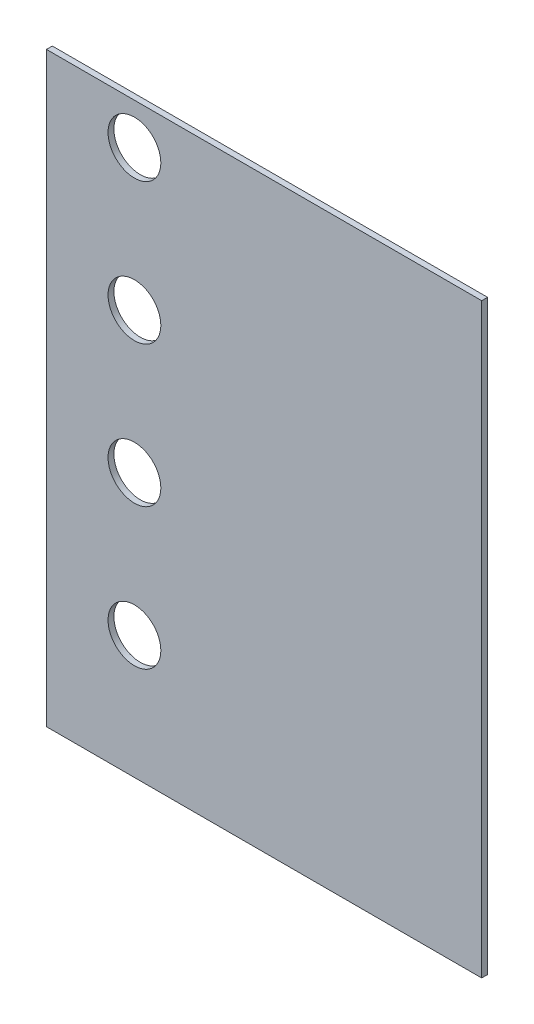
from build123d import *

# Parameters (mm, degrees)
SKETCH1_W           = 246.38
SKETCH1_H           = 254
BOSS_EXTRUDE1_DEPTH = 2.54
SKETCH3_R           = 11.43
CUT_EXTRUDE1_DEPTH  = 3.54
LPATTERN1_COUNT     = 4
LPATTERN1_PITCH     = 60.96
SKETCH4_W           = 57.912
SKETCH4_H           = 254
CUT_EXTRUDE2_DEPTH  = 3.54


with BuildPart() as part:
    # Sketch1 → Boss-Extrude1 (new body)
    with BuildSketch(Plane.XY):
        Rectangle(SKETCH1_W, SKETCH1_H)
    extrude(amount=BOSS_EXTRUDE1_DEPTH)

    # Sketch3 → Cut-Extrude1 (cut, through all)
    with BuildSketch(Plane.XY.offset(2.54)):
        with Locations((-85.09, 109.22)):
            Circle(SKETCH3_R)
    cut_extrude1 = extrude(amount=-CUT_EXTRUDE1_DEPTH, mode=Mode.SUBTRACT)

    # LPattern1: Cut-Extrude1 ×4
    with Locations(*[(0, -i * LPATTERN1_PITCH, 0) for i in range(1, LPATTERN1_COUNT)]):
        add(cut_extrude1, mode=Mode.SUBTRACT)

    # Sketch4 → Cut-Extrude2 (cut, through all)
    with BuildSketch(Plane.XY.offset(2.54)):
        with Locations((94.234, 0)):
            Rectangle(SKETCH4_W, SKETCH4_H)
    extrude(amount=-CUT_EXTRUDE2_DEPTH, mode=Mode.SUBTRACT)


solid = part.part
